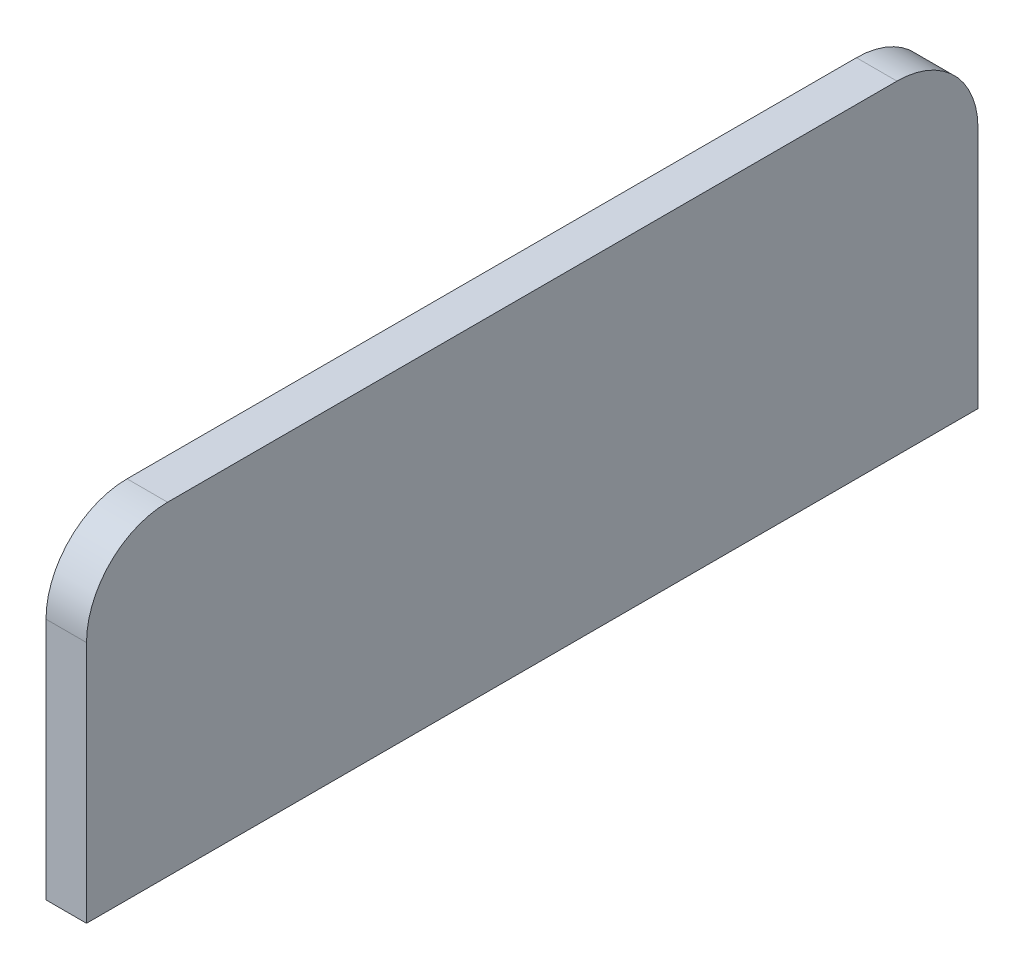
from build123d import *

# Parameters (mm, degrees)
SKETCH1_W           = 69.85
SKETCH1_H           = 25.4
BOSS_EXTRUDE1_DEPTH = 3.175
FILLET1_R           = 6.35


with BuildPart() as part:
    # Sketch1 → Boss-Extrude1 (new body)
    with BuildSketch(Plane(origin=(0, 0, 0), x_dir=(0, 0, -1), z_dir=(1, 0, 0))):
        Rectangle(SKETCH1_W, SKETCH1_H)
    extrude(amount=BOSS_EXTRUDE1_DEPTH)

    # Fillet1
    fillet1_edges = [part.edges().sort_by_distance(p)[0] for p in [
        (1.5875, 12.7, 34.925),
        (1.5875, 12.7, -34.925),
    ]]
    fillet(fillet1_edges, radius=FILLET1_R)


solid = part.part
